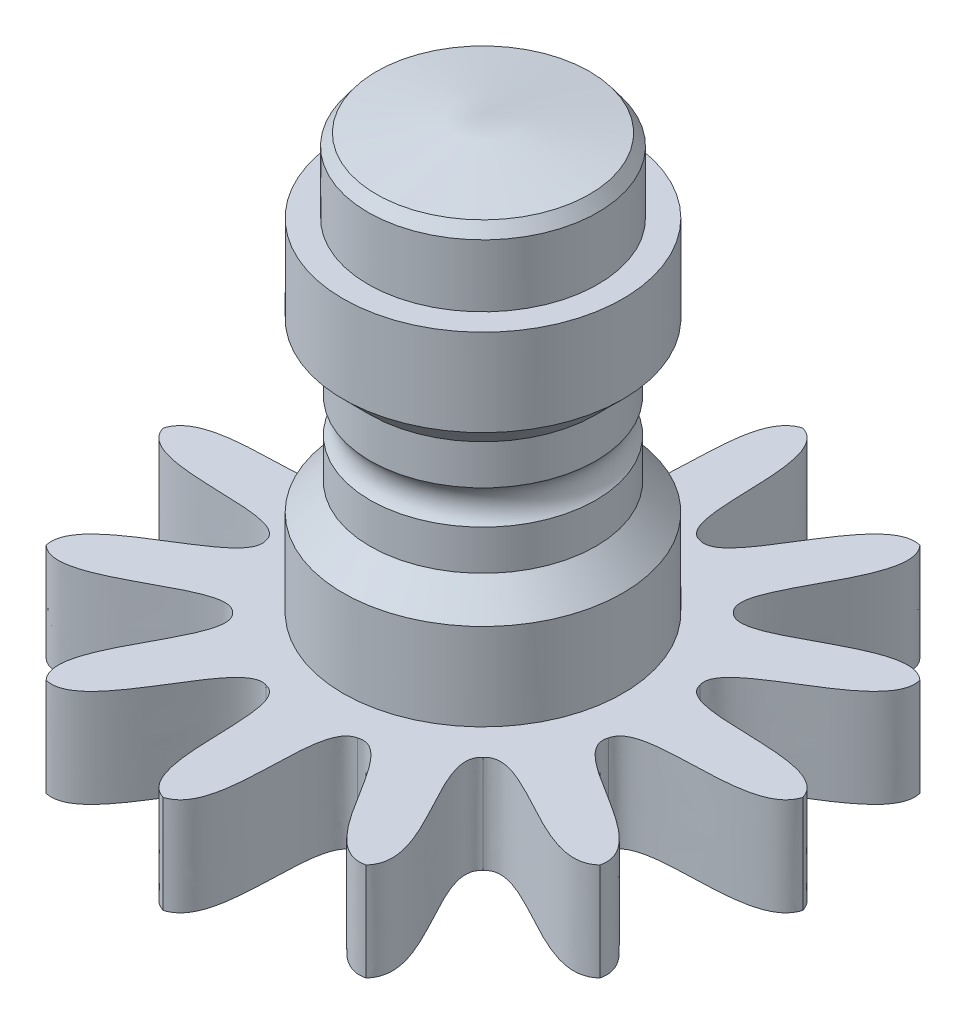
from build123d import *

# Parameters (mm, degrees)
BOSS_EXTRUDE1_12_TEETH_DEPTH = 0.49
SKETCH2_R                    = 0.7
BOSS_EXTRUDE2_DEPTH          = 1.71
SKETCH3_R                    = 0.575
BOSS_EXTRUDE3_DEPTH          = 0.45
CHAMFER1_SIZE                = 0.0875
CHAMFER1_SIZE2               = 0.575
CHAMFER2_SIZE2               = 0.0425
CHAMFER2_SIZE                = 0.05070529


with BuildPart() as part:
    # Sketch1 → Boss-Extrude1 (12 teeth) (new body)
    with BuildSketch(Plane(origin=(0, 0, 0), x_dir=(1, 0, 0), z_dir=(0, 1, 0))):
        with BuildLine():
            add(Edge.make_bspline(
                [(0, 1.6), (0.231150814, 1.531967472), (0.049245039, 0.890307389), (0.229443083, 0.856293245)],
                knots=[0, 0, 0, 0, 1, 1, 1, 1], degree=3))
            add(Edge.make_bspline(
                [(0.8, 1.385640646), (0.565801259, 1.442298155), (0.40250624, 0.795651335), (0.229443083, 0.856293245)],
                knots=[0, 0, 0, 0, 1, 1, 1, 1], degree=3))
            add(Edge.make_bspline(
                [(0.8, 1.385640646), (0.966166213, 1.211147341), (0.487801149, 0.746406297), (0.626850162, 0.626850162)],
                knots=[0, 0, 0, 0, 1, 1, 1, 1], degree=3))
            add(Edge.make_bspline(
                [(1.385640646, 0.8), (1.211147341, 0.966166213), (0.746406297, 0.487801149), (0.626850162, 0.626850162)],
                knots=[0, 0, 0, 0, 1, 1, 1, 1], degree=3))
            add(Edge.make_bspline(
                [(1.385640646, 0.8), (1.442298155, 0.565801259), (0.795651335, 0.40250624), (0.856293245, 0.229443083)],
                knots=[0, 0, 0, 0, 1, 1, 1, 1], degree=3))
            add(Edge.make_bspline(
                [(1.6, 0), (1.531967472, 0.231150814), (0.890307389, 0.049245039), (0.856293245, 0.229443083)],
                knots=[0, 0, 0, 0, 1, 1, 1, 1], degree=3))
            add(Edge.make_bspline(
                [(1.6, 0), (1.531967472, -0.231150814), (0.890307389, -0.049245039), (0.856293245, -0.229443083)],
                knots=[0, 0, 0, 0, 1, 1, 1, 1], degree=3))
            add(Edge.make_bspline(
                [(1.385640646, -0.8), (1.442298155, -0.565801259), (0.795651335, -0.40250624), (0.856293245, -0.229443083)],
                knots=[0, 0, 0, 0, 1, 1, 1, 1], degree=3))
            add(Edge.make_bspline(
                [(1.385640646, -0.8), (1.211147341, -0.966166213), (0.746406297, -0.487801149), (0.626850162, -0.626850162)],
                knots=[0, 0, 0, 0, 1, 1, 1, 1], degree=3))
            add(Edge.make_bspline(
                [(0.8, -1.385640646), (0.966166213, -1.211147341), (0.487801149, -0.746406297), (0.626850162, -0.626850162)],
                knots=[0, 0, 0, 0, 1, 1, 1, 1], degree=3))
            add(Edge.make_bspline(
                [(0.8, -1.385640646), (0.565801259, -1.442298155), (0.40250624, -0.795651335), (0.229443083, -0.856293245)],
                knots=[0, 0, 0, 0, 1, 1, 1, 1], degree=3))
            add(Edge.make_bspline(
                [(0, -1.6), (0.231150814, -1.531967472), (0.049245039, -0.890307389), (0.229443083, -0.856293245)],
                knots=[0, 0, 0, 0, 1, 1, 1, 1], degree=3))
            add(Edge.make_bspline(
                [(0, -1.6), (-0.231150814, -1.531967472), (-0.049245039, -0.890307389), (-0.229443083, -0.856293245)],
                knots=[0, 0, 0, 0, 1, 1, 1, 1], degree=3))
            add(Edge.make_bspline(
                [(-0.8, -1.385640646), (-0.565801259, -1.442298155), (-0.40250624, -0.795651335), (-0.229443083, -0.856293245)],
                knots=[0, 0, 0, 0, 1, 1, 1, 1], degree=3))
            add(Edge.make_bspline(
                [(-0.8, -1.385640646), (-0.966166213, -1.211147341), (-0.487801149, -0.746406297), (-0.626850162, -0.626850162)],
                knots=[0, 0, 0, 0, 1, 1, 1, 1], degree=3))
            add(Edge.make_bspline(
                [(-1.385640646, -0.8), (-1.211147341, -0.966166213), (-0.746406297, -0.487801149), (-0.626850162, -0.626850162)],
                knots=[0, 0, 0, 0, 1, 1, 1, 1], degree=3))
            add(Edge.make_bspline(
                [(-1.385640646, -0.8), (-1.442298155, -0.565801259), (-0.795651335, -0.40250624), (-0.856293245, -0.229443083)],
                knots=[0, 0, 0, 0, 1, 1, 1, 1], degree=3))
            add(Edge.make_bspline(
                [(-1.6, 0), (-1.531967472, -0.231150814), (-0.890307389, -0.049245039), (-0.856293245, -0.229443083)],
                knots=[0, 0, 0, 0, 1, 1, 1, 1], degree=3))
            add(Edge.make_bspline(
                [(-1.6, 0), (-1.531967472, 0.231150814), (-0.890307389, 0.049245039), (-0.856293245, 0.229443083)],
                knots=[0, 0, 0, 0, 1, 1, 1, 1], degree=3))
            add(Edge.make_bspline(
                [(-1.385640646, 0.8), (-1.442298155, 0.565801259), (-0.795651335, 0.40250624), (-0.856293245, 0.229443083)],
                knots=[0, 0, 0, 0, 1, 1, 1, 1], degree=3))
            add(Edge.make_bspline(
                [(-1.385640646, 0.8), (-1.211147341, 0.966166213), (-0.746406297, 0.487801149), (-0.626850162, 0.626850162)],
                knots=[0, 0, 0, 0, 1, 1, 1, 1], degree=3))
            add(Edge.make_bspline(
                [(-0.8, 1.385640646), (-0.966166213, 1.211147341), (-0.487801149, 0.746406297), (-0.626850162, 0.626850162)],
                knots=[0, 0, 0, 0, 1, 1, 1, 1], degree=3))
            add(Edge.make_bspline(
                [(-0.8, 1.385640646), (-0.565801259, 1.442298155), (-0.40250624, 0.795651335), (-0.229443083, 0.856293245)],
                knots=[0, 0, 0, 0, 1, 1, 1, 1], degree=3))
            add(Edge.make_bspline(
                [(0, 1.6), (-0.231150814, 1.531967472), (-0.049245039, 0.890307389), (-0.229443083, 0.856293245)],
                knots=[0, 0, 0, 0, 1, 1, 1, 1], degree=3))
        make_face()
    extrude(amount=BOSS_EXTRUDE1_12_TEETH_DEPTH)

    # Sketch2 → Boss-Extrude2 (add)
    with BuildSketch(Plane(origin=(0, 0.49, 0), x_dir=(1, 0, 0), z_dir=(0, 1, 0))):
        Circle(SKETCH2_R)
    extrude(amount=BOSS_EXTRUDE2_DEPTH)

    # Sketch3 → Boss-Extrude3 (add)
    with BuildSketch(Plane(origin=(0, 2.2, 0), x_dir=(1, 0, 0), z_dir=(0, 1, 0))):
        Circle(SKETCH3_R)
    extrude(amount=BOSS_EXTRUDE3_DEPTH)

    # Chamfer1
    chamfer1_edges = [part.edges().sort_by_distance(p)[0] for p in [
        (-0.575, 2.65, 0),
    ]]
    chamfer1_side = [part.faces().sort_by_distance(p)[0] for p in [
        (-0.575, 2.425, 0),
    ]]
    chamfer(chamfer1_edges, length=CHAMFER1_SIZE, length2=CHAMFER1_SIZE2, reference=chamfer1_side[0])

    # Chamfer2
    chamfer2_edges = [part.edges().sort_by_distance(p)[0] for p in [
        (-0.575, 2.5625, 0),
    ]]
    chamfer(chamfer2_edges, length=CHAMFER2_SIZE, length2=CHAMFER2_SIZE2)

    # Sketch4 → Cut-Revolve2 (revolve, cut)
    with BuildSketch(Plane.XY):
        with BuildLine():
            Line((0.811069311, 1.876069311), (0.565, 1.63))
            Line((0.565, 1.63), (0.565, 1.430005353))
            ThreePointArc((0.565, 1.430005353), (0.5297, 1.345), (0.565, 1.259994647))
            Line((0.565, 1.259994647), (0.565, 1.06))
            Line((0.565, 1.06), (0.811069311, 0.813930689))
            Line((0.811069311, 0.813930689), (0.811069311, 1.876069311))
        make_face()
    revolve(axis=Axis((0, -1000, 0), (0, 1, 0)), mode=Mode.SUBTRACT)

    # Sketch5 → Cut-Revolve3 (revolve, cut)
    with BuildSketch(Plane.XY):
        Polygon((0, 0), (0, 2.28), (0.375, 2.063493649), (0.375, 0), align=None)
    revolve(axis=Axis((0, -1000, 0), (0, 1, 0)), mode=Mode.SUBTRACT)


solid = part.part
